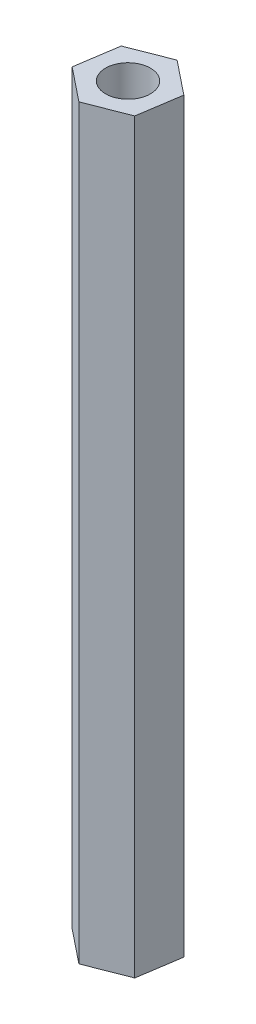
from build123d import *

# Parameters (mm, degrees)
SKETCH1_R           = 1.5
BOSS_EXTRUDE1_DEPTH = 50


with BuildPart() as part:
    # Sketch1 → Boss-Extrude1 (new body)
    with BuildSketch(Plane(origin=(0, 0, 0), x_dir=(1, 0, 0), z_dir=(0, 1, 0))):
        Polygon((2.254174087, -1.803339269), (2.688824662, 1.050502389), (0.434650576, 2.853841658), (-2.254174087, 1.803339269), (-2.688824662, -1.050502389), (-0.434650576, -2.853841658), align=None)
        Circle(SKETCH1_R, mode=Mode.SUBTRACT)
    extrude(amount=BOSS_EXTRUDE1_DEPTH)


solid = part.part
